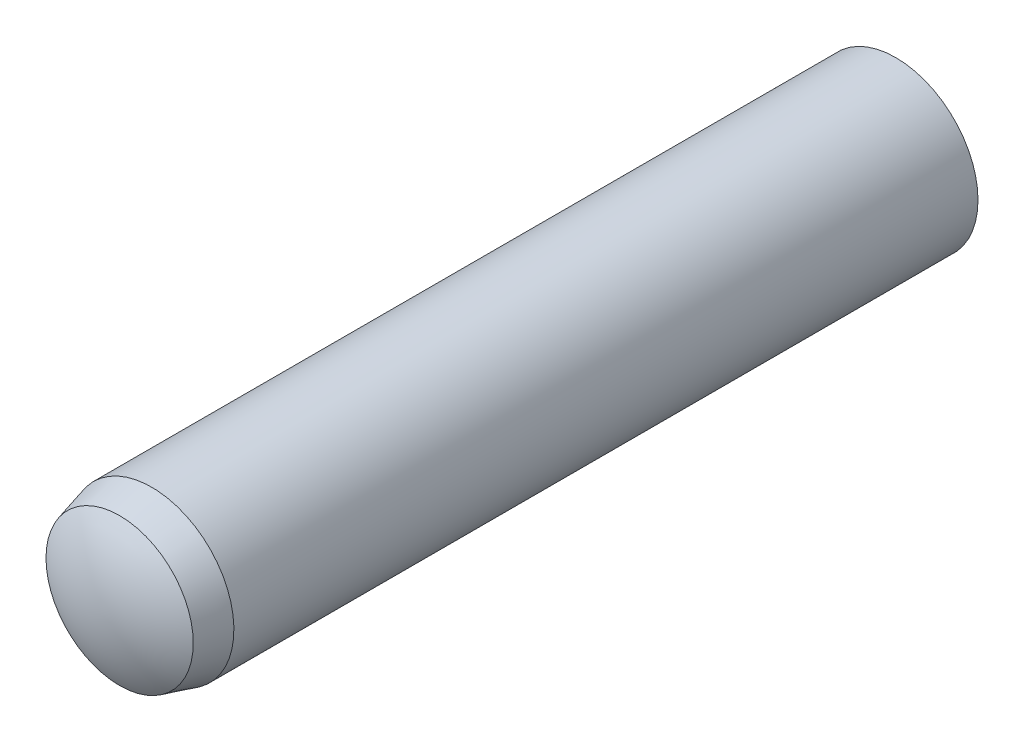
from build123d import *


with BuildPart() as part:
    # Sketch3 → Revolve1 (revolve)
    with BuildSketch(Plane(origin=(0, 0, 0), x_dir=(0, 0, -1), z_dir=(1, 0, 0))):
        with BuildLine():
            Line((-10, 0), (10, 0))
            ThreePointArc((10, 0), (9.846768836, 1.044030651), (9.4, 2))
            Line((9.4, 2), (-8.7, 2))
            Line((-8.7, 2), (-9.48, 1.79099963))
            ThreePointArc((-9.48, 1.79099963), (-9.867370053, 0.932480519), (-10, 0))
        make_face()
    revolve(axis=Axis((0, 0, 10), (0, 0, -1)))


solid = part.part
